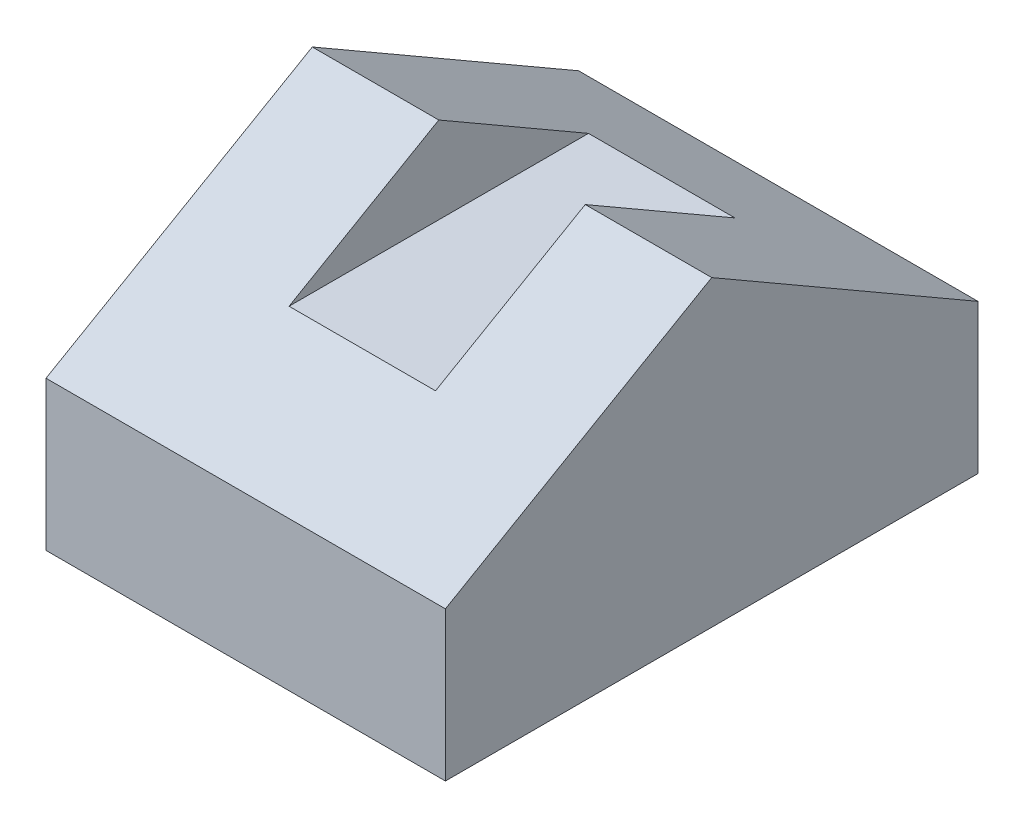
from build123d import *

# Parameters (mm, degrees)
BOSS_EXTRUDE1_DEPTH     = 0.15
SKETCH2_W               = 0.055
SKETCH2_H               = 0.03246
CUT_EXTRUDE1_DEPTH      = 1.1
CUT_EXTRUDE1_DEPTH_BACK = 1.1


with BuildPart() as part:
    # Sketch1 → Boss-Extrude1 (new body)
    with BuildSketch(Plane(origin=(0, 0, 0), x_dir=(0, 0, -1), z_dir=(1, 0, 0))):
        Polygon((0.1, 0.056), (0, 0.113735027), (-0.1, 0.056), (-0.1, 0), (0.1, 0), align=None)
    extrude(amount=BOSS_EXTRUDE1_DEPTH)

    # Sketch2 → Cut-Extrude1 (cut, two sides)
    with BuildSketch(Plane.XY) as cut_extrude1_sk:
        with Locations((0.075, 0.097505027)):
            Rectangle(SKETCH2_W, SKETCH2_H)
    extrude(amount=CUT_EXTRUDE1_DEPTH, mode=Mode.SUBTRACT)
    extrude(cut_extrude1_sk.sketch, amount=-CUT_EXTRUDE1_DEPTH_BACK, mode=Mode.SUBTRACT)


solid = part.part
